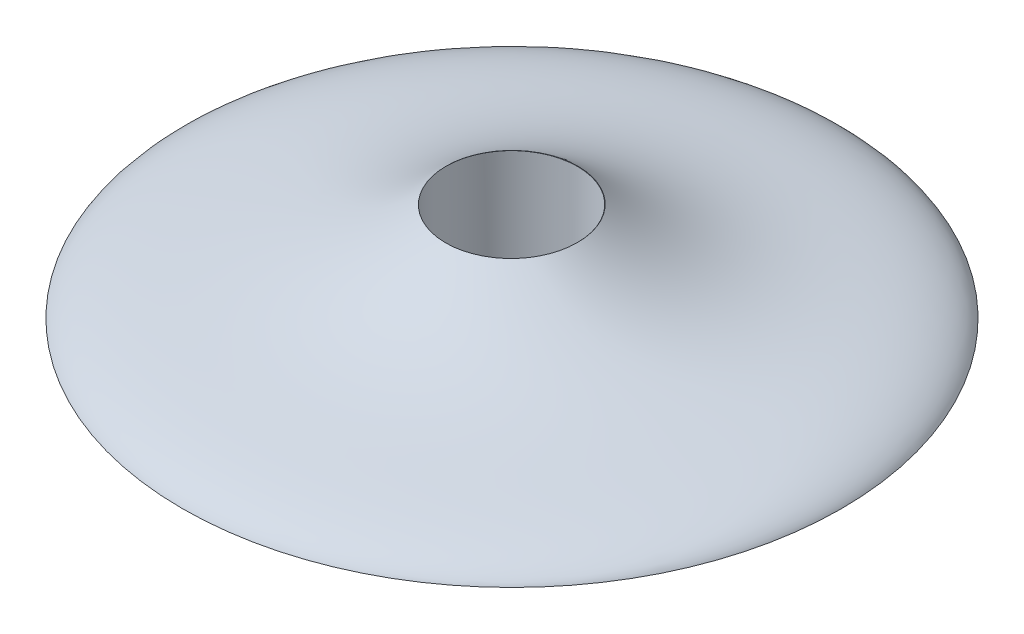
from build123d import *

# Parameters (mm, degrees)
SKETCH_3_R          = 20
CUT_EXTRUDE_1_DEPTH = 58


with BuildPart() as part:
    # 草图2 → 旋转1 (revolve)
    with BuildSketch(Plane(origin=(0, 0, 0), x_dir=(0, 0, -1), z_dir=(1, 0, 0))):
        with BuildLine():
            Line((-77.026638721, 21.899743781), (-77.026638721, -8.100256219))
            Line((-77.026638721, -8.100256219), (22.973361279, -8.100256219))
            add(Edge.make_bspline(
                [(22.973361279, -8.100256219), (19.99930936, -2.493347022), (-0.022077456, 5.04834586), (-26.437409059, -4.115118329), (-57.026638721, 21.899743781)],
                knots=[0, 0, 0, 0, 0, 1, 1, 1, 1, 1], degree=4))
            Line((-57.026638721, 21.899743781), (-77.026638721, 21.899743781))
        make_face()
    revolve(axis=Axis((0, 21.899743781, 77.026638721), (0, -1, 0)))

    # 草图3 → 切除-拉伸1 (cut)
    with BuildSketch(Plane(origin=(0, 21.899743781, 0), x_dir=(1, 0, 0), z_dir=(0, 1, 0))):
        with Locations(Location((0, -77.152414432, 0), (0, 0, 270))):  # turned: the seam where the file's is
            Circle(SKETCH_3_R)
    extrude(amount=-CUT_EXTRUDE_1_DEPTH, mode=Mode.SUBTRACT)


solid = part.part
